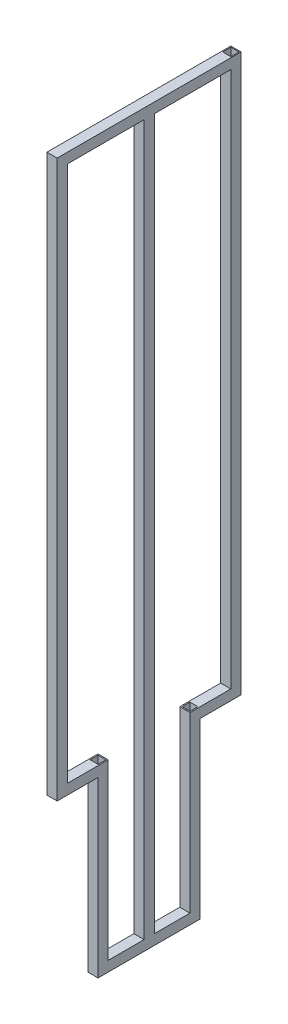
from build123d import *

# Parameters (mm, degrees)
SKETCH1_W           = 2
SKETCH1_H           = 2
SKETCH1_W_2         = 1.6
SKETCH1_H_2         = 1.6
BOSS_EXTRUDE1_DEPTH = 109
SKETCH2_W           = 2
SKETCH2_H           = 2
SKETCH2_W_2         = 1.6
SKETCH2_H_2         = 1.6
BOSS_EXTRUDE2_DEPTH = 34
SKETCH3_W           = 2
SKETCH3_H           = 2
SKETCH3_W_2         = 1.6
SKETCH3_H_2         = 1.6
BOSS_EXTRUDE3_DEPTH = 6
SKETCH7_W           = 2
SKETCH7_H           = 2
SKETCH7_W_2         = 1.54
SKETCH7_H_2         = 1.54
BOSS_EXTRUDE4_DEPTH = 36
BOSS_EXTRUDE5_REACH = 28
SKETCH8_W           = 2
SKETCH8_H           = 2
SKETCH8_W_2         = 1.6
SKETCH8_H_2         = 1.6
SCALE2_SCALE        = 10
BOSS_EXTRUDE6_REACH = 1412
SKETCH9_W           = 20
SKETCH9_H           = 20
SKETCH9_W_2         = 16
SKETCH9_H_2         = 16


with BuildPart() as part:
    # Sketch1 → Boss-Extrude1 (new body)
    with BuildSketch(Plane(origin=(0, 0, 0), x_dir=(1, 0, 0), z_dir=(0, 1, 0))):
        Rectangle(SKETCH1_W, SKETCH1_H)
        Rectangle(SKETCH1_W_2, SKETCH1_H_2, mode=Mode.SUBTRACT)
    boss_extrude1 = extrude(amount=BOSS_EXTRUDE1_DEPTH)

    # Sketch2 → Boss-Extrude2 (add)
    with BuildSketch(Plane.XY.offset(1)):
        with Locations((0, 108)):
            Rectangle(SKETCH2_W, SKETCH2_H)
        with Locations((0, 108)):
            Rectangle(SKETCH2_W_2, SKETCH2_H_2, mode=Mode.SUBTRACT)
    extrude(amount=BOSS_EXTRUDE2_DEPTH)

    # Mirror1: Boss-Extrude1 across plane
    add(boss_extrude1.mirror(Plane.XY.offset(17)))

    # Sketch3 → Boss-Extrude3 (add)
    with BuildSketch(Plane.XY.offset(1)):
        with Locations((0, 1)):
            Rectangle(SKETCH3_W, SKETCH3_H)
        with Locations((0, 1)):
            Rectangle(SKETCH3_W_2, SKETCH3_H_2, mode=Mode.SUBTRACT)
    boss_extrude3 = extrude(amount=BOSS_EXTRUDE3_DEPTH)

    # Sketch7 → Boss-Extrude4 (add)
    with BuildSketch(Plane(origin=(0, 2, 0), x_dir=(1, 0, 0), z_dir=(0, 1, 0))):
        with Locations((0, -8)):
            Rectangle(SKETCH7_W, SKETCH7_H)
        with Locations((0, -8)):
            Rectangle(SKETCH7_W_2, SKETCH7_H_2, mode=Mode.SUBTRACT)
    boss_extrude4 = extrude(amount=-BOSS_EXTRUDE4_DEPTH)

    # Mirror2: Boss-Extrude3, Boss-Extrude4 across plane
    add(boss_extrude3.mirror(Plane.XY.offset(17)))
    add(boss_extrude4.mirror(Plane.XY.offset(17)))

    # Sketch8 → Boss-Extrude5 (add, up to next)
    with BuildSketch(Plane(origin=(0, 0, 25), x_dir=(-1, 0, 0), z_dir=(0, 0, -1)), mode=Mode.PRIVATE) as boss_extrude5_sk1:
        with Locations((0, -33)):
            Rectangle(SKETCH8_W, SKETCH8_H)
        with Locations((0, -33)):
            Rectangle(SKETCH8_W_2, SKETCH8_H_2, mode=Mode.SUBTRACT)
    boss_extrude5_tool1 = extrude(boss_extrude5_sk1.sketch, amount=BOSS_EXTRUDE5_REACH, mode=Mode.PRIVATE) - part.part
    add(boss_extrude5_tool1.solids().sort_by_distance((0, -32.028284, 25))[0])


with BuildPart() as part_1:
    # Scale2: scaled about (0, 0, 0)
    add(part.part.scale(SCALE2_SCALE))

    # Sketch9 → Boss-Extrude6 (add, up to next)
    with BuildSketch(Plane.XZ.offset(-1070), mode=Mode.PRIVATE) as boss_extrude6_sk1:
        with Locations((0, 169.738105544)):
            Rectangle(SKETCH9_W, SKETCH9_H)
        with Locations((0, 169.738105544)):
            Rectangle(SKETCH9_W_2, SKETCH9_H_2, mode=Mode.SUBTRACT)
    boss_extrude6_tool1 = extrude(boss_extrude6_sk1.sketch, amount=BOSS_EXTRUDE6_REACH, mode=Mode.PRIVATE) - part_1.part
    add(boss_extrude6_tool1.solids().sort_by_distance((0, 1070, 179.455263))[0])


solid = part_1.part
